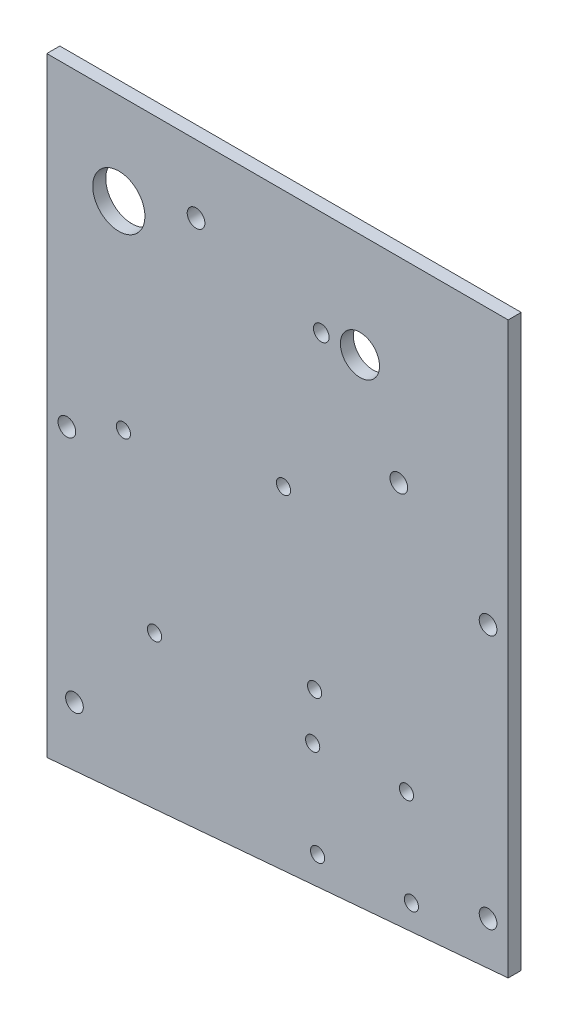
from build123d import *

# Parameters (mm, degrees)
BOSS_EXTRUDE1_DEPTH               = 3.175
F_6_CLEARANCE_HOLE1_D             = 4.3053
F_4_CLEARANCE_HOLE1_D             = 3.4544
F_6_CLEARANCE_HOLE2_D             = 4.3053
F_3_8_0_375_DIAMETER_HOLE1_D      = 9.525
F_1_2_0_5_DIAMETER_HOLE1_D        = 12.7
OBOGS_ROTARY_ANTI_ROTATION_HOLE_D = 3.81


with BuildPart() as part:
    # Sketch1 → Boss-Extrude1 (new body)
    with BuildSketch(Plane.XY):
        Polygon((112.268, 0), (0, 0), (0, -148.336), (112.268, -138.684), align=None)
    extrude(amount=-BOSS_EXTRUDE1_DEPTH)

    # #6 Clearance Hole1 (through all)
    with Locations(Plane.XY):
        with Locations((6.731, -133.35), (107.3785, -128.5875), (107.3785, -66.675), (4.8895, -76.2)):
            Hole(F_6_CLEARANCE_HOLE1_D / 2)

    # #4 Clearance Hole1 (through all)
    with Locations(Plane.XY):
        with Locations((18.644469576, -70.03220158), (57.60279842, -62.459469576), (65.175530424, -101.41779842), (26.21720158, -108.990530424), (65.891864398, -135.837535562), (88.720535562, -134.641135602), (87.524135602, -111.812464438), (64.695464438, -113.008864398)):
            Hole(F_4_CLEARANCE_HOLE1_D / 2)

    # #6 Clearance Hole2 (through all)
    with Locations(Plane.XY):
        with Locations((36.322, -16.51), (85.6615, -47.625)):
            Hole(F_6_CLEARANCE_HOLE2_D / 2)

    # 3/8 (0.375) Diameter Hole1 (through all)
    with Locations(Plane.XY):
        with Locations((76.2, -25.4)):
            Hole(F_3_8_0_375_DIAMETER_HOLE1_D / 2)

    # 1/2 (0.5) Diameter Hole1 (through all)
    with Locations(Plane.XY):
        with Locations((17.526, -22.352)):
            Hole(F_1_2_0_5_DIAMETER_HOLE1_D / 2)

    # OBOGS Rotary Anti Rotation Hole (through all)
    with Locations(Plane(origin=(0, 0, -3.175), x_dir=(-1, 0, 0), z_dir=(0, 0, -1))):
        with Locations((-66.792027829, -25.458354734)):
            Hole(OBOGS_ROTARY_ANTI_ROTATION_HOLE_D / 2)


solid = part.part
